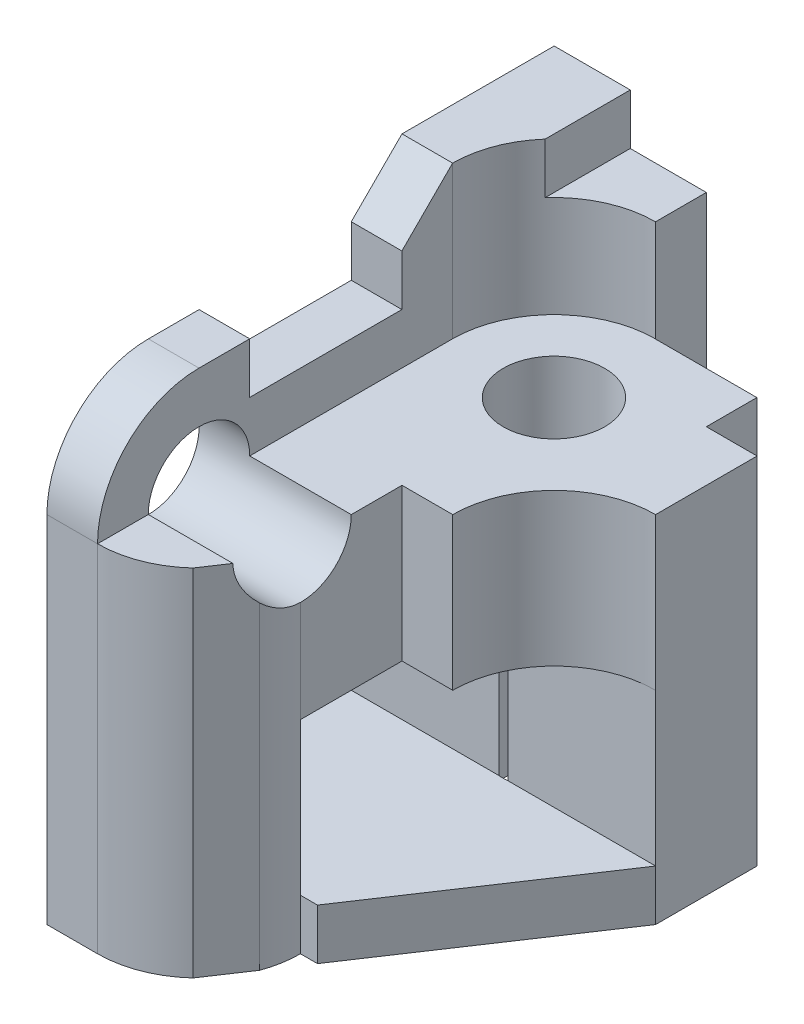
from build123d import *

# Parameters (mm, degrees)
BOSS_EXTRUDE1_DEPTH = 10
CUT_EXTRUDE3_DEPTH  = 8
SKETCH5_R           = 1
CUT_EXTRUDE5_DEPTH  = 7.5
CUT_EXTRUDE7_DEPTH  = 2
CUT_EXTRUDE10_DEPTH = 4
CUT_EXTRUDE12_DEPTH = 7
CUT_EXTRUDE14_DEPTH = 6
CUT_EXTRUDE15_DEPTH = 7
SKETCH18_W          = 1.999299567
SKETCH18_H          = 4.5
CUT_EXTRUDE29_DEPTH = 2
CUT_EXTRUDE30_DEPTH = 2
CUT_EXTRUDE31_DEPTH = 7
CUT_EXTRUDE33_DEPTH = 10


with BuildPart() as part:
    # Sketch1 → Boss-Extrude1 (new body)
    with BuildSketch(Plane.XY):
        Polygon((0, 0), (0, 7), (-3, 7), (-3, 9), (-4.5, 9), (-4.5, 10), (-6, 10), (-6, 0), align=None)
    extrude(amount=BOSS_EXTRUDE1_DEPTH)

    # Sketch3 → Cut-Extrude3 (cut, through all)
    with BuildSketch(Plane(origin=(0, 7, 0), x_dir=(1, 0, 0), z_dir=(0, 1, 0))):
        Polygon((-3, 0), (-3, -1.004111064), (-1, -1.004111064), (-1, -2), (0, -2), (0, 0), align=None)
    extrude(amount=-CUT_EXTRUDE3_DEPTH, mode=Mode.SUBTRACT)

    # Sketch5 → Cut-Extrude5 (cut, symmetric)
    with BuildSketch(Plane(origin=(0, 7, 0), x_dir=(1, 0, 0), z_dir=(0, 1, 0))):
        with Locations((-3, -3.004111064)):
            Circle(SKETCH5_R)
    extrude(amount=CUT_EXTRUDE5_DEPTH, both=True, mode=Mode.SUBTRACT)

    # Sketch7 → Cut-Extrude7 (cut, symmetric)
    with BuildSketch(Plane(origin=(0, 9, 0), x_dir=(1, 0, 0), z_dir=(0, 1, 0))):
        with BuildLine():
            Line((-3, -1.002055532), (-3, -2.004111064))
            ThreePointArc((-3, -2.004111064), (-4, -3.004111064), (-3, -4.004111064))
            Line((-3, -4.004111064), (-3, -10))
            Line((-3, -10), (-5.002055532, -10))
            Line((-5.002055532, -10), (-5.002055532, -3.004111064))
            ThreePointArc((-5.002055532, -3.004111064), (-4.415667043, -1.588444021), (-3, -1.002055532))
        make_face()
    extrude(amount=CUT_EXTRUDE7_DEPTH, both=True, mode=Mode.SUBTRACT)

    # Sketch8 → Cut-Extrude10 (cut)
    with BuildSketch(Plane.ZY.offset(6)):
        Polygon((3, 10), (4, 9), (4, 8), (7, 8), (7, 10), align=None)
    extrude(amount=-CUT_EXTRUDE10_DEPTH, mode=Mode.SUBTRACT)

    # Sketch9 → Cut-Extrude12 (cut, symmetric)
    with BuildSketch(Plane(origin=(-5.002055532, 0, 0), x_dir=(0, 0, -1), z_dir=(1, 0, 0))):
        with BuildLine():
            Line((-8, 9), (-7, 9))
            Line((-7, 9), (-7, 10))
            Line((-7, 10), (-10, 10))
            Line((-10, 10), (-10, 7))
            ThreePointArc((-10, 7), (-9.414213562, 8.414213562), (-8, 9))
        make_face()
        with BuildLine():
            ThreePointArc((-7, 7), (-8, 8), (-9, 7))
            Line((-9, 7), (-7, 7))
        make_face()
        with BuildLine():
            Line((-7, 7), (-9, 7))
            ThreePointArc((-9, 7), (-8, 6), (-7, 7))
        make_face()
    extrude(amount=CUT_EXTRUDE12_DEPTH, both=True, mode=Mode.SUBTRACT)

    # Sketch10 → Cut-Extrude14 (cut)
    with BuildSketch(Plane(origin=(0, 7, 0), x_dir=(1, 0, 0), z_dir=(0, 1, 0))):
        with BuildLine():
            Line((-2, -6), (-3, -6))
            Line((-3, -6), (-3, -8.001400867))
            Line((-3, -8.001400867), (0, -8))
            Line((0, -8), (0, -4))
            ThreePointArc((0, -4), (-1.414213562, -4.585786438), (-2, -6))
        make_face()
    extrude(amount=-CUT_EXTRUDE14_DEPTH, mode=Mode.SUBTRACT)

    # Sketch12 → Cut-Extrude15 (cut, through all)
    with BuildSketch(Plane(origin=(0, 0, 0), x_dir=(0, 0, -1), z_dir=(1, 0, 0))):
        Polygon((-4, 1), (-4, 4), (-8.001400867, 4), (-8, 1), align=None)
    extrude(amount=-CUT_EXTRUDE15_DEPTH, mode=Mode.SUBTRACT)

    # Sketch18 → Cut-Extrude29 (cut)
    with BuildSketch(Plane(origin=(0, 0, 0), x_dir=(0, 0, -1), z_dir=(1, 0, 0))):
        with Locations((-9.000350216, 4.75)):
            Rectangle(SKETCH18_W, SKETCH18_H)
    extrude(amount=-CUT_EXTRUDE29_DEPTH, mode=Mode.SUBTRACT)

    # Sketch21 → Cut-Extrude30 (cut)
    with BuildSketch(Plane.XY.offset(8.000700433)):
        Polygon((0, 6.000000245), (-1.5, 6.000000981), (-1.5, 4), (0, 4), align=None)
    extrude(amount=-CUT_EXTRUDE30_DEPTH, mode=Mode.SUBTRACT)

    # Sketch22 → Cut-Extrude31 (cut)
    with BuildSketch(Plane(origin=(0, 7, 0), x_dir=(1, 0, 0), z_dir=(0, 1, 0))):
        Polygon((0, -4), (-4, -10), (0, -10), align=None)
    extrude(amount=-CUT_EXTRUDE31_DEPTH, mode=Mode.SUBTRACT)

    # Sketch23 → Cut-Extrude33 (cut)
    with BuildSketch(Plane(origin=(0, 7, 0), x_dir=(1, 0, 0), z_dir=(0, 1, 0))):
        with BuildLine():
            Line((-3.002055532, -8), (-0.668346428, -8))
            Line((-0.668346428, -8), (-0.668346428, -10.987104512))
            Line((-0.668346428, -10.987104512), (-5.156575053, -10.987104512))
            Line((-5.156575053, -10.987104512), (-5.002055532, -10))
            ThreePointArc((-5.002055532, -10), (-3.587841969, -9.414213562), (-3.002055532, -8))
        make_face()
    extrude(amount=-CUT_EXTRUDE33_DEPTH, mode=Mode.SUBTRACT)


solid = part.part
